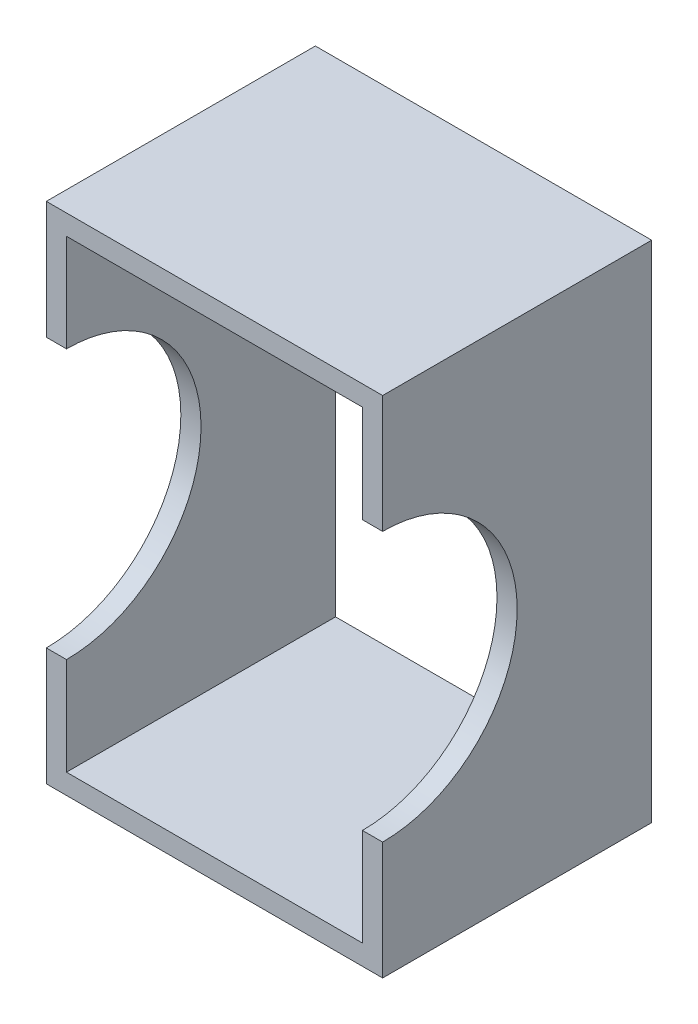
from build123d import *

# Parameters (mm, degrees)
SKETCH1_W               = 100
SKETCH1_H               = 150
SKETCH1_W_2             = 88
SKETCH1_H_2             = 138
BOSS_EXTRUDE1_DEPTH     = 80
SKETCH2_R               = 40
CUT_EXTRUDE1_DEPTH      = 51
CUT_EXTRUDE1_DEPTH_BACK = 51


with BuildPart() as part:
    # Sketch1 → Boss-Extrude1 (new body)
    with BuildSketch(Plane.XY):
        Rectangle(SKETCH1_W, SKETCH1_H)
        Rectangle(SKETCH1_W_2, SKETCH1_H_2, mode=Mode.SUBTRACT)
    extrude(amount=-BOSS_EXTRUDE1_DEPTH)

    # Sketch2 → Cut-Extrude1 (cut, two sides)
    with BuildSketch(Plane(origin=(0, 0, 0), x_dir=(0, 0, -1), z_dir=(1, 0, 0))) as cut_extrude1_sk:
        Circle(SKETCH2_R)
    extrude(amount=CUT_EXTRUDE1_DEPTH, mode=Mode.SUBTRACT)
    extrude(cut_extrude1_sk.sketch, amount=-CUT_EXTRUDE1_DEPTH_BACK, mode=Mode.SUBTRACT)


solid = part.part
